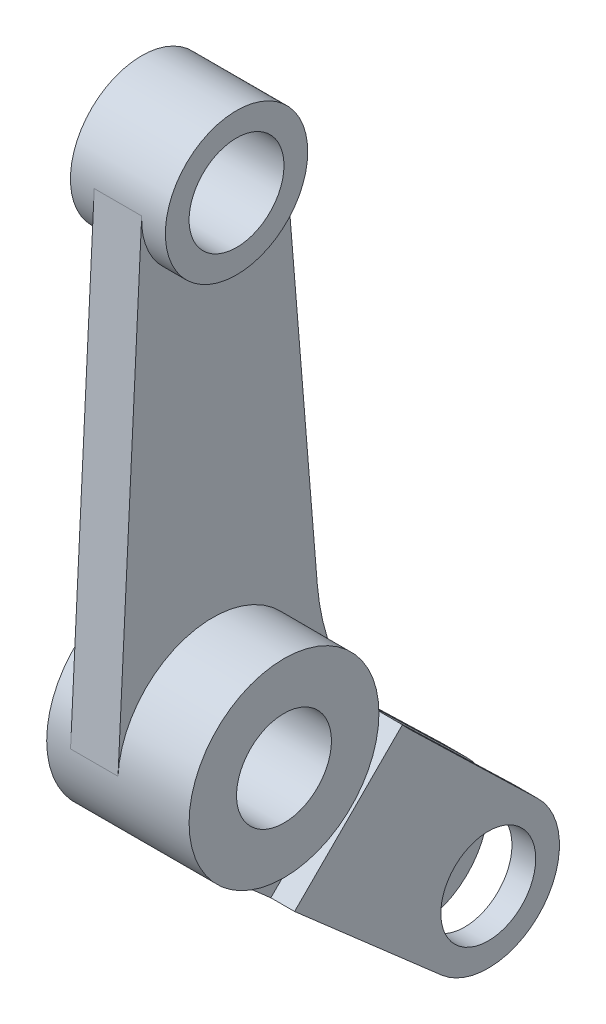
from build123d import *

# Parameters (mm, degrees)
IZIM1_R                     = 20
Y_KSEKLIK_EKSTR_ZYON1_DEPTH = 10
IZIM2_R                     = 15
Y_KSEKLIK_EKSTR_ZYON2_DEPTH = 5
IZIM3_R                     = 20
Y_KSEKLIK_EKSTR_ZYON3_DEPTH = 15
IZIM4_R                     = 20
Y_KSEKLIK_EKSTR_ZYON4_DEPTH = 5
IZIM5_R                     = 10
KES_EKSTR_ZYON1_DEPTH       = 11
KES_EKSTR_ZYON1_DEPTH_BACK  = 21
Y_KSEKLIK_EKSTR_ZYON5_DEPTH = 5
KES_EKSTR_ZYON3_START       = -5
IZIM8_W                     = 10
IZIM8_H                     = 55.466945175
KES_EKSTR_ZYON3_DEPTH       = 90
IZIM9_R                     = 10
KES_EKSTR_ZYON4_DEPTH       = 21


with BuildPart() as part:
    # Çizim1 → Yükseklik-Ekstrüzyon1 (new body)
    with BuildSketch(Plane(origin=(0, 0, 0), x_dir=(0, 0, -1), z_dir=(1, 0, 0))):
        with BuildLine():
            Line((22.00493217, 15.116319136), (14.949905951, 101.224872265))
            ThreePointArc((14.949905951, 101.224872265), (-0.237952402, 114.998112503), (-14.981238267, 100.75))
            Line((-14.981238267, 100.75), (-19.974984355, 1))
            ThreePointArc((-19.974984355, 1), (0.500156421, 19.993745111), (20, 0))
            ThreePointArc((20, 0), (8.265673223, -18.212046732), (-13.167864617, -15.053482701))
            Line((-13.167864617, -15.053482701), (43.157110126, -64.323120614))
            ThreePointArc((43.157110126, -64.323120614), (64.073343656, -63.187367339), (63.459512577, -42.249316522))
            Line((63.459512577, -42.249316522), (37.082938713, -16.746413538))
            ThreePointArc((37.082938713, -16.746413538), (26.642905037, -2.187865906), (22.00493217, 15.116319136))
        make_face()
        Circle(IZIM1_R)
    extrude(amount=Y_KSEKLIK_EKSTR_ZYON1_DEPTH)

    # Çizim2 → Yükseklik-Ekstrüzyon2 (add)
    with BuildSketch(Plane(origin=(10, 0, 0), x_dir=(0, 0, -1), z_dir=(1, 0, 0))):
        with Locations((0, 100)):
            Circle(IZIM2_R)
    y_kseklik_ekstr_zyon2 = extrude(amount=Y_KSEKLIK_EKSTR_ZYON2_DEPTH)

    # Aynalama1: Yükseklik-Ekstrüzyon2 across plane
    add(y_kseklik_ekstr_zyon2.mirror(Plane(origin=(5, 0, 0), x_dir=(0, 0, 1), z_dir=(1, 0, 0))))

    # Çizim3 → Yükseklik-Ekstrüzyon3 (add)
    with BuildSketch(Plane(origin=(10, 0, 0), x_dir=(0, 0, -1), z_dir=(1, 0, 0))):
        Circle(IZIM3_R)
    extrude(amount=Y_KSEKLIK_EKSTR_ZYON3_DEPTH)

    # Çizim4 → Yükseklik-Ekstrüzyon4 (add)
    with BuildSketch(Plane.ZY):
        Circle(IZIM4_R)
    extrude(amount=Y_KSEKLIK_EKSTR_ZYON4_DEPTH)

    # Çizim5 → Kes-Ekstrüzyon1 (cut, two sides)
    with BuildSketch(Plane(origin=(15, 0, 0), x_dir=(0, 0, -1), z_dir=(1, 0, 0))) as kes_ekstr_zyon1_sk:
        with Locations((0, 100)):
            Circle(IZIM5_R)
        Circle(IZIM5_R)
    extrude(amount=KES_EKSTR_ZYON1_DEPTH, mode=Mode.SUBTRACT)
    extrude(kes_ekstr_zyon1_sk.sketch, amount=-KES_EKSTR_ZYON1_DEPTH_BACK, mode=Mode.SUBTRACT)

    # Çizim6 → Yükseklik-Ekstrüzyon5 (add)
    with BuildSketch(Plane(origin=(10, 0, 0), x_dir=(0, 0, -1), z_dir=(1, 0, 0))):
        with BuildLine():
            ThreePointArc((37.082938713, -16.746413538), (35.998094477, -15.664861033), (34.94689158, -14.550583103))
            Line((34.94689158, -14.550583103), (12.228664173, -37.26881051))
            Line((12.228664173, -37.26881051), (43.157110126, -64.323120614))
            ThreePointArc((43.157110126, -64.323120614), (64.073343656, -63.187367339), (63.459512577, -42.249316522))
            Line((63.459512577, -42.249316522), (37.082938713, -16.746413538))
        make_face()
    y_kseklik_ekstr_zyon5 = extrude(amount=Y_KSEKLIK_EKSTR_ZYON5_DEPTH)

    # Aynalama2: Yükseklik-Ekstrüzyon5 across plane
    add(y_kseklik_ekstr_zyon5.mirror(Plane(origin=(5, 0, 0), x_dir=(0, 0, 1), z_dir=(1, 0, 0))))

    # Çizim8 → Kes-Ekstrüzyon3 (cut)
    with BuildSketch(Plane(origin=(0, -24.748737342, -24.748737342), x_dir=(1, 0, 0), z_dir=(0, 0.707106781, 0.707106781)).offset(KES_EKSTR_ZYON3_START)):
        with Locations((5, -5.759989705)):
            Rectangle(IZIM8_W, IZIM8_H)
    extrude(amount=-KES_EKSTR_ZYON3_DEPTH, mode=Mode.SUBTRACT)

    # Çizim9 → Kes-Ekstrüzyon4 (cut, through all)
    with BuildSketch(Plane(origin=(15, 0, 0), x_dir=(0, 0, -1), z_dir=(1, 0, 0))):
        with Locations((53.033008589, -53.033008589)):
            Circle(IZIM9_R)
    extrude(amount=-KES_EKSTR_ZYON4_DEPTH, mode=Mode.SUBTRACT)


solid = part.part
